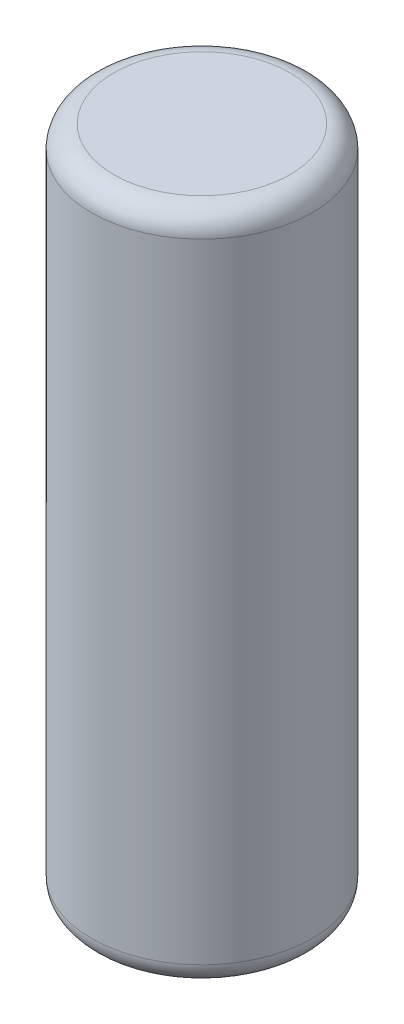
from build123d import *

# Parameters (mm, degrees)
SKETCH1_R           = 10
BOSS_EXTRUDE1_DEPTH = 61
FILLET1_R           = 2


with BuildPart() as part:
    # Sketch1 → Boss-Extrude1 (new body)
    with BuildSketch(Plane(origin=(0, 0, 0), x_dir=(1, 0, 0), z_dir=(0, 1, 0))):
        Circle(SKETCH1_R)
    extrude(amount=BOSS_EXTRUDE1_DEPTH)

    # Fillet1
    fillet1_edges = [part.edges().sort_by_distance(p)[0] for p in [
        (-10, 0, 0),
        (-10, 61, 0),
    ]]
    fillet(fillet1_edges, radius=FILLET1_R)


solid = part.part
